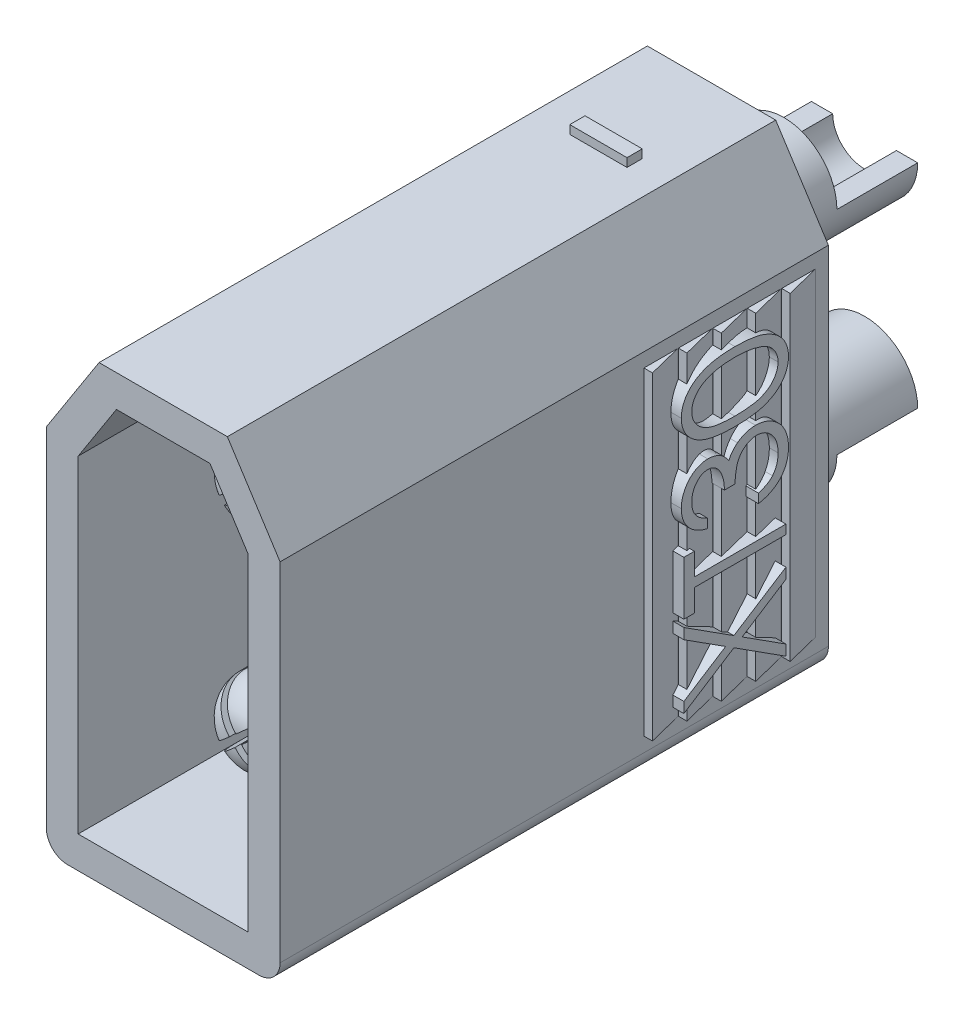
from build123d import *

# Parameters (mm, degrees)
BOSS_EXTRUDE2_DEPTH        = 12.9
BOSS_EXTRUDE3_START        = 1.45
BOSS_EXTRUDE3_DEPTH        = 3.55
BOSS_EXTRUDE4_START        = 1
BOSS_EXTRUDE4_DEPTH        = 7.5
SKETCH7_R                  = 1.25
BOSS_EXTRUDE5_DEPTH        = 5
BOSS_EXTRUDE5_DEPTH_BACK   = 3.6
BOSS_EXTRUDE5_2_DEPTH      = 5
BOSS_EXTRUDE5_2_DEPTH_BACK = 3.6
SKETCH8_R                  = 0.75
CUT_EXTRUDE1_DEPTH         = 3
SKETCH9_W                  = 1.9
SKETCH9_H                  = 1.25
CUT_EXTRUDE2_DEPTH         = 3.95
CUT_EXTRUDE2_DEPTH_BACK    = 3.95
CHAMFER1_SIZE              = 0.75
CHAMFER3_SIZE              = 0.75
SKETCH10_R                 = 0.97
BOSS_EXTRUDE6_DEPTH        = 6.2
BOSS_EXTRUDE6_2_DEPTH      = 6.2
FILLET1_R                  = 0.8
FILLET2_R                  = 0.8
CUT_EXTRUDE3_DEPTH         = 3.1
BOSS_EXTRUDE7_DEPTH        = 0.2
SKETCH13_W                 = 1.346153847
SKETCH13_H                 = 0.358974359
BOSS_EXTRUDE8_DEPTH        = 0.2
BOSS_EXTRUDE9_DEPTH        = 0.3
BOSS_EXTRUDE10_DEPTH       = 0.3


with BuildPart() as part:
    # Sketch3 → Boss-Extrude2 (new body)
    with BuildSketch(Plane.XY):
        with BuildLine():
            Line((2.25, 0.160364397), (-2.25, 0.160364397))
            ThreePointArc((-2.25, 0.160364397), (-2.603553391, 0.306811006), (-2.75, 0.660364397))
            Line((-2.75, 0.660364397), (-2.75, 8.830640811))
            Line((-2.75, 8.830640811), (-1.509463409, 10.760364397))
            Line((-1.509463409, 10.760364397), (1.509463409, 10.760364397))
            Line((1.509463409, 10.760364397), (2.75, 8.830640811))
            Line((2.75, 8.830640811), (2.75, 0.660364397))
            ThreePointArc((2.75, 0.660364397), (2.603553391, 0.306811006), (2.25, 0.160364397))
        make_face()
        Polygon((2, 0.910364397), (-2, 0.910364397), (-2, 8.610364397), (-1.1, 10.010364397), (1.1, 10.010364397), (2, 8.610364397), align=None, mode=Mode.SUBTRACT)
    extrude(amount=BOSS_EXTRUDE2_DEPTH)

    # Sketch4 → Boss-Extrude3 (add)
    with BuildSketch(Plane.XY.offset(BOSS_EXTRUDE3_START)):
        with BuildLine():
            Line((-1.5, 10.010364397), (1.5, 10.010364397))
            ThreePointArc((1.5, 10.010364397), (1.853553391, 9.863917787), (2, 9.510364397))
            Line((2, 9.510364397), (2, 0.910364397))
            Line((2, 0.910364397), (-2, 0.910364397))
            Line((-2, 0.910364397), (-2, 9.510364397))
            ThreePointArc((-2, 9.510364397), (-1.853553391, 9.863917787), (-1.5, 10.010364397))
        make_face()
    extrude(amount=BOSS_EXTRUDE3_DEPTH)

    # Sketch6 → Boss-Extrude4 (add)
    with BuildSketch(Plane(origin=(0, 0, 0), x_dir=(1, 0, 0), z_dir=(0, 1, 0)).offset(BOSS_EXTRUDE4_START)):
        Polygon((2.75, -0.3), (2.75, -1.1), (2.95, -1.1), align=None)
        Polygon((2.75, -1.11), (2.75, -1.91), (2.95, -1.91), align=None)
        Polygon((2.75, -1.92), (2.75, -2.72), (2.95, -2.72), align=None)
        Polygon((2.75, -2.73), (2.75, -3.53), (2.95, -3.53), align=None)
        Polygon((2.75, -3.54), (2.75, -4.34), (2.95, -4.34), align=None)
        Polygon((-2.95, -4.34), (-2.75, -3.54), (-2.75, -4.34), align=None)
        Polygon((-2.95, -3.53), (-2.75, -2.73), (-2.75, -3.53), align=None)
        Polygon((-2.95, -2.72), (-2.75, -1.92), (-2.75, -2.72), align=None)
        Polygon((-2.95, -1.91), (-2.75, -1.11), (-2.75, -1.91), align=None)
        Polygon((-2.95, -1.1), (-2.75, -0.3), (-2.75, -1.1), align=None)
    extrude(amount=BOSS_EXTRUDE4_DEPTH)

    # Sketch12 → Boss-Extrude7 (add)
    with BuildSketch(Plane.XZ.offset(-0.160364397)):
        Polygon((-0.148717949, 2.884615385), (-0.148717949, 3.916666667), (0.165384615, 3.916666667), (0.165384615, 2.884615385), (1.197435897, 2.884615385), (1.197435897, 2.570512821), (0.165384615, 2.570512821), (0.165384615, 1.538461538), (-0.148717949, 1.538461538), (-0.148717949, 2.570512821), (-1.180769231, 2.570512821), (-1.180769231, 2.884615385), align=None)
    extrude(amount=BOSS_EXTRUDE7_DEPTH)

    # Sketch13 → Boss-Extrude8 (add)
    with BuildSketch(Plane(origin=(0, 10.760364397, 0), x_dir=(-1, 0, 0), z_dir=(0, 1, 0))):
        with Locations((-0.052168047, 2.534824587)):
            Rectangle(SKETCH13_W, SKETCH13_H)
    extrude(amount=BOSS_EXTRUDE8_DEPTH)

    # Sketch14 → Boss-Extrude9 (add)
    with BuildSketch(Plane.ZY.offset(2.75)):
        Polygon((3.7, 8.211538462), (3.7, 7.962980769), (2.718269231, 7.334615385), (3.7, 6.70625), (3.7, 6.457692308), (2.524038462, 7.210096154), (1.3, 6.426923077), (1.3, 6.675480769), (2.329807692, 7.334615385), (1.3, 7.99375), (1.3, 8.242307692), (2.524038462, 7.458653846), align=None)
        Polygon((3.453846154, 6.288461538), (3.7, 6.288461538), (3.7, 5.026923077), (3.453846154, 5.026923077), (3.453846154, 5.55), (1.3, 5.55), (1.3, 5.765384615), (3.453846154, 5.765384615), align=None)
        with BuildLine():
            Line((3.146153846, 4.503846154), (3.146153846, 4.719230769))
            add(Edge.make_bspline(
                [(3.146153846, 4.719230769), (3.170313264, 4.713395649), (3.217542949, 4.701988466), (3.285022214, 4.678195844), (3.348878343, 4.652276354), (3.40791565, 4.621152397), (3.463320612, 4.587203537), (3.513836583, 4.548307957), (3.560748331, 4.506260147), (3.602380265, 4.45975161), (3.64007928, 4.410977671), (3.672222176, 4.359251074), (3.699873024, 4.305612519), (3.722652611, 4.24969037), (3.73981297, 4.191318138), (3.752263351, 4.131023539), (3.760348687, 4.068648568), (3.761137781, 4.026307363), (3.761538462, 4.004807692)],
                knots=[0, 0, 0, 0, 7.4513e-05, 0.000145667, 0.000214417, 0.000281078, 0.000345646, 0.000409109, 0.000472075, 0.000534362, 0.000596096, 0.000656791, 0.000716781, 0.000776954, 0.000837647, 0.00089903, 0.000961524, 0.001025992, 0.001025992, 0.001025992, 0.001025992], degree=3))
            add(Edge.make_bspline(
                [(3.761538462, 4.004807692), (3.760592704, 3.973482383), (3.758721818, 3.911515062), (3.741637633, 3.820477544), (3.714603256, 3.732687725), (3.677249843, 3.649106526), (3.631178543, 3.57147103), (3.57634558, 3.502394787), (3.513808916, 3.442814094), (3.444735158, 3.392829378), (3.370914237, 3.353692236), (3.294936987, 3.324833008), (3.216983635, 3.307263856), (3.164350072, 3.304986903), (3.137980769, 3.303846154)],
                knots=[0, 0, 0, 0, 9.3899e-05, 0.00018575, 0.000276839, 0.000368952, 0.000459731, 0.000546978, 0.000632671, 0.00071807, 0.00080195, 0.000882585, 0.000961327, 0.001040384, 0.001040384, 0.001040384, 0.001040384], degree=3))
            add(Edge.make_bspline(
                [(3.137980769, 3.303846154), (3.112604681, 3.304644045), (3.062947616, 3.306205394), (2.990452875, 3.319462792), (2.922127206, 3.341773372), (2.85768298, 3.372678352), (2.797528805, 3.412683987), (2.741529337, 3.461145264), (2.689436199, 3.518404233), (2.659594275, 3.561795504), (2.644230769, 3.584134615)],
                knots=[0, 0, 0, 0, 7.6085e-05, 0.000148886, 0.000220191, 0.000291151, 0.000362622, 0.000436254, 0.000512835, 0.000594098, 0.000594098, 0.000594098, 0.000594098], degree=3))
            add(Edge.make_bspline(
                [(2.644230769, 3.584134615), (2.63190288, 3.558604269), (2.607477766, 3.50802127), (2.559576676, 3.439072335), (2.504269466, 3.376481792), (2.46110879, 3.341576385), (2.439423077, 3.324038462)],
                knots=[0, 0, 0, 0, 8.4934e-05, 0.00016828, 0.000251007, 0.000334546, 0.000334546, 0.000334546, 0.000334546], degree=3))
            add(Edge.make_bspline(
                [(2.439423077, 3.324038462), (2.423613732, 3.312485412), (2.392253932, 3.289568501), (2.341804337, 3.261361383), (2.290962579, 3.235479451), (2.237729623, 3.216431099), (2.183815408, 3.199993125), (2.128065414, 3.189177486), (2.071009313, 3.182234278), (2.032392143, 3.18125931), (2.012980769, 3.180769231)],
                knots=[0, 0, 0, 0, 5.8685e-05, 0.00011641, 0.000173173, 0.000229612, 0.000285747, 0.00034213, 0.000399736, 0.000457959, 0.000457959, 0.000457959, 0.000457959], degree=3))
            add(Edge.make_bspline(
                [(2.012980769, 3.180769231), (1.97937544, 3.182002464), (1.912322928, 3.184463127), (1.813234502, 3.206368134), (1.716541423, 3.240522701), (1.623676369, 3.288177011), (1.536970145, 3.347137911), (1.45974361, 3.417672544), (1.39291464, 3.498066224), (1.33725751, 3.587792791), (1.292734208, 3.684961717), (1.261839895, 3.788901588), (1.241716319, 3.898100993), (1.239558549, 3.972986084), (1.238461538, 4.011057692)],
                knots=[0, 0, 0, 0, 0.000100706, 0.000200938, 0.000302971, 0.000407683, 0.000513164, 0.00061662, 0.000720404, 0.000825792, 0.000932506, 0.001040031, 0.001150374, 0.001264488, 0.001264488, 0.001264488, 0.001264488], degree=3))
            add(Edge.make_bspline(
                [(1.238461538, 4.011057692), (1.239056885, 4.036716641), (1.240228328, 4.087204896), (1.248236511, 4.161429009), (1.262862801, 4.232278174), (1.282545067, 4.299848184), (1.307499405, 4.364199066), (1.338575083, 4.425134453), (1.375131542, 4.483029237), (1.417600288, 4.537337089), (1.465107492, 4.588051536), (1.518496527, 4.633824832), (1.576780462, 4.675420119), (1.640636272, 4.711723643), (1.709238734, 4.744388981), (1.783466275, 4.771255923), (1.862655319, 4.79490317), (1.917840055, 4.805897546), (1.946153846, 4.811538462)],
                knots=[0, 0, 0, 0, 7.6977e-05, 0.000151465, 0.000223595, 0.00029373, 0.000362386, 0.000430329, 0.000498619, 0.000567476, 0.000636857, 0.000706734, 0.000778104, 0.000851332, 0.000926819, 0.001005766, 0.00108792, 0.001174485, 0.001174485, 0.001174485, 0.001174485], degree=3))
            Line((1.946153846, 4.811538462), (1.946153846, 4.596153846))
            add(Edge.make_bspline(
                [(1.946153846, 4.596153846), (1.927674523, 4.590542446), (1.891730634, 4.579627786), (1.840000138, 4.561048839), (1.792577473, 4.539882024), (1.749114761, 4.517174898), (1.709183971, 4.493326821), (1.673840975, 4.466642301), (1.641533408, 4.439097744), (1.623331388, 4.418334759), (1.614423077, 4.408173077)],
                knots=[0, 0, 0, 0, 5.7934e-05, 0.000112687, 0.000164772, 0.000213586, 0.00025976, 0.000304088, 0.00034633, 0.00038682, 0.00038682, 0.00038682, 0.00038682], degree=3))
            add(Edge.make_bspline(
                [(1.614423077, 4.408173077), (1.604063077, 4.394735424), (1.583375055, 4.367901598), (1.556973938, 4.324174811), (1.534097806, 4.278187461), (1.516623272, 4.228943113), (1.501827162, 4.177504413), (1.49214452, 4.123039934), (1.485501203, 4.066030185), (1.484914964, 4.027103719), (1.484615385, 4.007211538)],
                knots=[0, 0, 0, 0, 5.0866e-05, 0.000101575, 0.000152964, 0.000204677, 0.000258103, 0.00031336, 0.000370434, 0.000430081, 0.000430081, 0.000430081, 0.000430081], degree=3))
            add(Edge.make_bspline(
                [(1.484615385, 4.007211538), (1.485037033, 3.98475169), (1.485861529, 3.940833395), (1.493465896, 3.87675431), (1.504492464, 3.815774027), (1.521740161, 3.758514848), (1.542431622, 3.704197617), (1.569520542, 3.654034852), (1.600113099, 3.606551829), (1.635698125, 3.563139581), (1.674161687, 3.524001317), (1.714968099, 3.490181532), (1.756852096, 3.460889731), (1.800790747, 3.437344011), (1.846353049, 3.418718241), (1.893709543, 3.406046248), (1.942461457, 3.397233195), (1.975601388, 3.396515597), (1.992307692, 3.396153846)],
                knots=[0, 0, 0, 0, 6.7351e-05, 0.000131698, 0.000193364, 0.000252999, 0.000310851, 0.000367413, 0.000423685, 0.000480075, 0.000535489, 0.000588058, 0.000638867, 0.000688556, 0.000737302, 0.000786173, 0.000835413, 0.000885471, 0.000885471, 0.000885471, 0.000885471], degree=3))
            add(Edge.make_bspline(
                [(1.992307692, 3.396153846), (2.014669779, 3.397203177), (2.05928268, 3.399296618), (2.12491721, 3.415279923), (2.188157598, 3.441568341), (2.247915784, 3.478376614), (2.303327092, 3.523161948), (2.352574163, 3.575490823), (2.393618756, 3.635491603), (2.421872315, 3.691070581), (2.440702124, 3.740419384), (2.453905233, 3.782567182), (2.464459565, 3.829794668), (2.474668782, 3.881534884), (2.483227542, 3.938006046), (2.490395838, 3.99925903), (2.496122592, 4.065318479), (2.498681403, 4.111049473), (2.5, 4.134615385)],
                knots=[0, 0, 0, 0, 6.7036e-05, 0.000133738, 0.000201416, 0.000271748, 0.000343529, 0.00041462, 0.000486501, 0.000560894, 0.000601072, 0.000644867, 0.000693263, 0.000746158, 0.00080307, 0.000864552, 0.000931149, 0.001001954, 0.001001954, 0.001001954, 0.001001954], degree=3))
            Line((2.5, 4.134615385), (2.746153846, 4.134615385))
            add(Edge.make_bspline(
                [(2.746153846, 4.134615385), (2.746659909, 4.104923977), (2.74765116, 4.046765804), (2.759557156, 3.961798157), (2.776212077, 3.880451678), (2.801133952, 3.804583191), (2.831047314, 3.735657242), (2.864776815, 3.675530146), (2.902990827, 3.62562689), (2.945187826, 3.585822797), (2.990973089, 3.556608006), (3.038193773, 3.534679412), (3.087948546, 3.521823981), (3.121884535, 3.520098217), (3.138942308, 3.519230769)],
                knots=[0, 0, 0, 0, 8.9006e-05, 0.000174341, 0.000256944, 0.000337827, 0.000413394, 0.00048209, 0.000544117, 0.000601265, 0.000655139, 0.000706348, 0.000756954, 0.000808099, 0.000808099, 0.000808099, 0.000808099], degree=3))
            add(Edge.make_bspline(
                [(3.138942308, 3.519230769), (3.151475649, 3.519514904), (3.176410136, 3.520080176), (3.212838313, 3.527210223), (3.248154898, 3.537922039), (3.282199645, 3.552657938), (3.314774944, 3.572345731), (3.345920757, 3.59597764), (3.376159056, 3.623565073), (3.404043204, 3.655829025), (3.430345097, 3.690758195), (3.453082104, 3.728681243), (3.472353977, 3.768761731), (3.488276651, 3.811036515), (3.500246646, 3.855674947), (3.508843236, 3.902458453), (3.514217465, 3.951478695), (3.514991259, 3.984922153), (3.515384615, 4.001923077)],
                knots=[0, 0, 0, 0, 3.7549e-05, 7.4703e-05, 0.000110898, 0.000148144, 0.00018566, 0.000224794, 0.000265285, 0.000308205, 0.000352533, 0.000396314, 0.00044061, 0.000485795, 0.00053163, 0.00057906, 0.000628383, 0.000679381, 0.000679381, 0.000679381, 0.000679381], degree=3))
            add(Edge.make_bspline(
                [(3.515384615, 4.001923077), (3.514432389, 4.029250838), (3.51257247, 4.082628311), (3.496224619, 4.159563101), (3.470323134, 4.231010572), (3.439047168, 4.285439132), (3.408279997, 4.325699299), (3.381810999, 4.355020423), (3.351800577, 4.383288989), (3.317425578, 4.409395714), (3.27986802, 4.434904968), (3.238921049, 4.459573177), (3.194000885, 4.482607996), (3.162411731, 4.496629667), (3.146153846, 4.503846154)],
                knots=[0, 0, 0, 0, 8.1902e-05, 0.000159973, 0.000234813, 0.000309114, 0.000347192, 0.00038668, 0.000427497, 0.000470676, 0.000516013, 0.00056367, 0.000613986, 0.000667343, 0.000667343, 0.000667343, 0.000667343], degree=3))
        make_face()
        with BuildLine():
            add(Edge.make_bspline(
                [(2.499038462, 2.965384615), (2.537505242, 2.965159689), (2.612227517, 2.964722765), (2.721108414, 2.959862134), (2.823252613, 2.951787614), (2.918664999, 2.940721985), (3.007370214, 2.927255947), (3.089131173, 2.909279594), (3.164326392, 2.888836595), (3.233200736, 2.865143267), (3.296683291, 2.838409551), (3.355943811, 2.809309064), (3.410907058, 2.776702805), (3.462398728, 2.742398603), (3.509844149, 2.705142892), (3.553153471, 2.665328627), (3.592352846, 2.622560867), (3.627908811, 2.577685461), (3.658882589, 2.530418809), (3.686792023, 2.482217984), (3.709699001, 2.432232443), (3.728521186, 2.380918072), (3.743602926, 2.328424096), (3.754047002, 2.274533615), (3.760592629, 2.219233611), (3.761220193, 2.181909617), (3.761538462, 2.162980769)],
                knots=[0, 0, 0, 0, 0.000115394, 0.000224154, 0.000326883, 0.000422716, 0.000512269, 0.000595913, 0.00067371, 0.00074593, 0.000814236, 0.000880244, 0.000943816, 0.001005821, 0.001065739, 0.0011246, 0.001182102, 0.001239617, 0.001296154, 0.001351493, 0.001406561, 0.001460863, 0.001515345, 0.00157022, 0.001625383, 0.001682146, 0.001682146, 0.001682146, 0.001682146], degree=3))
            add(Edge.make_bspline(
                [(3.761538462, 2.162980769), (3.76120396, 2.143893584), (3.760538741, 2.105935178), (3.75414518, 2.049816063), (3.74353641, 1.994993425), (3.728504885, 1.941700987), (3.709856421, 1.889500996), (3.686482397, 1.838801745), (3.659274031, 1.789288317), (3.627303373, 1.741747549), (3.591658383, 1.695657527), (3.551363982, 1.652150352), (3.506827031, 1.611222065), (3.458524039, 1.572358998), (3.405528552, 1.536663732), (3.348762306, 1.502670521), (3.28723257, 1.472243982), (3.221965963, 1.442940205), (3.151156597, 1.417646271), (3.075203618, 1.394835131), (2.99320989, 1.376403839), (2.905605608, 1.361051195), (2.812069048, 1.349157552), (2.712800717, 1.340495169), (2.607735307, 1.335919339), (2.535901353, 1.335057601), (2.499038462, 1.334615385)],
                knots=[0, 0, 0, 0, 5.7244e-05, 0.00011384, 0.000169187, 0.000224594, 0.000279799, 0.000335305, 0.000391901, 0.000449104, 0.000506999, 0.000566538, 0.000626757, 0.000688326, 0.000752333, 0.000818295, 0.000886667, 0.000958132, 0.001032807, 0.001112058, 0.001195912, 0.001284754, 0.001378794, 0.001478689, 0.001583607, 0.001694201, 0.001694201, 0.001694201, 0.001694201], degree=3))
            add(Edge.make_bspline(
                [(2.499038462, 1.334615385), (2.46233649, 1.335062738), (2.390824197, 1.335934387), (2.286229632, 1.340437871), (2.187494777, 1.349350593), (2.094344793, 1.360374224), (2.00733274, 1.376077235), (1.925631239, 1.393928791), (1.849945361, 1.416116359), (1.779509438, 1.441065535), (1.714562595, 1.46973345), (1.653564755, 1.500428903), (1.596844827, 1.534213456), (1.543850111, 1.570121601), (1.495128206, 1.608654337), (1.450558698, 1.649755931), (1.410170985, 1.69345767), (1.374038974, 1.739651897), (1.342440476, 1.787940548), (1.314196501, 1.837288706), (1.291278267, 1.888681315), (1.271927958, 1.940976215), (1.256861852, 1.994666843), (1.246546191, 2.049700536), (1.239291373, 2.105897061), (1.238739108, 2.14388698), (1.238461538, 2.162980769)],
                knots=[0, 0, 0, 0, 0.000110113, 0.000214551, 0.000313966, 0.00040747, 0.000495838, 0.000579117, 0.000658232, 0.000732291, 0.000803123, 0.000871066, 0.000937028, 0.001001035, 0.00106298, 0.001123199, 0.001182739, 0.001241308, 0.001298912, 0.001355742, 0.001411685, 0.001467506, 0.001522914, 0.001578733, 0.001635384, 0.001692628, 0.001692628, 0.001692628, 0.001692628], degree=3))
            add(Edge.make_bspline(
                [(1.238461538, 2.162980769), (1.23878287, 2.181908848), (1.239416472, 2.219231325), (1.245917863, 2.274542438), (1.25651944, 2.328348871), (1.270916329, 2.380758187), (1.289213921, 2.431877644), (1.31248778, 2.481206477), (1.339481837, 2.529396148), (1.370192627, 2.576226767), (1.405386394, 2.620805771), (1.444309654, 2.663388571), (1.487938683, 2.702899968), (1.535575131, 2.739688746), (1.586814803, 2.7745993), (1.642162448, 2.806886042), (1.701978203, 2.835929766), (1.765811202, 2.863262607), (1.835191738, 2.887356454), (1.910788018, 2.908478489), (1.993018222, 2.926086659), (2.081638235, 2.940247241), (2.176714385, 2.951921216), (2.278414071, 2.9598239), (2.38664955, 2.964726636), (2.460891856, 2.965161287), (2.499038462, 2.965384615)],
                knots=[0, 0, 0, 0, 5.6763e-05, 0.000111926, 0.000166801, 0.000221154, 0.000274839, 0.000329471, 0.000384573, 0.000440444, 0.000497285, 0.000554786, 0.000613322, 0.00067362, 0.000735226, 0.000799213, 0.000865651, 0.000934588, 0.001007419, 0.001085808, 0.001169922, 0.001259552, 0.001354964, 0.001457214, 0.001565494, 0.001679926, 0.001679926, 0.001679926, 0.001679926], degree=3))
        make_face()
        with BuildLine():
            add(Edge.make_bspline(
                [(2.5, 2.75), (2.467943749, 2.749918093), (2.405728861, 2.749759129), (2.315322054, 2.745606306), (2.230999542, 2.739949004), (2.152654262, 2.732652113), (2.080551391, 2.721815812), (2.014195056, 2.709673993), (1.953936316, 2.69489823), (1.899362024, 2.677415701), (1.849544813, 2.657503965), (1.803192165, 2.635760049), (1.759742093, 2.612413867), (1.719635907, 2.586240321), (1.682474377, 2.557833083), (1.648364296, 2.527145508), (1.617454495, 2.494231565), (1.580777019, 2.448667879), (1.542427413, 2.388811558), (1.509443824, 2.313008014), (1.488581598, 2.235082492), (1.485935923, 2.182176334), (1.484615385, 2.155769231)],
                knots=[0, 0, 0, 0, 9.6159e-05, 0.000186625, 0.000271437, 0.0003497, 0.000422587, 0.000490101, 0.000552017, 0.000608577, 0.000661875, 0.000712848, 0.000762114, 0.00080972, 0.000856357, 0.000902313, 0.000947208, 0.000991657, 0.001077683, 0.001159498, 0.001238907, 0.00131804, 0.00131804, 0.00131804, 0.00131804], degree=3))
            add(Edge.make_bspline(
                [(1.484615385, 2.155769231), (1.485711006, 2.129192542), (1.487899986, 2.076094034), (1.50901912, 1.998516575), (1.540883947, 1.92320439), (1.578562237, 1.864183631), (1.61444452, 1.819281315), (1.645037421, 1.787109665), (1.679292873, 1.757581403), (1.71625239, 1.729575409), (1.756622094, 1.703889185), (1.80020786, 1.680531605), (1.847130725, 1.65921731), (1.879887117, 1.647073964), (1.896634615, 1.640865385)],
                knots=[0, 0, 0, 0, 7.9573e-05, 0.000158981, 0.000239533, 0.000324231, 0.000368005, 0.000411871, 0.000457189, 0.000503535, 0.00055088, 0.00060057, 0.000651778, 0.000705348, 0.000705348, 0.000705348, 0.000705348], degree=3))
            add(Edge.make_bspline(
                [(1.896634615, 1.640865385), (1.918049294, 1.633629887), (1.961530275, 1.618938723), (2.028979636, 1.600004935), (2.099747246, 1.585093804), (2.173410183, 1.571678925), (2.250511692, 1.562522543), (2.330813213, 1.555152614), (2.41437529, 1.550811572), (2.471148998, 1.550273457), (2.5, 1.55)],
                knots=[0, 0, 0, 0, 6.7807e-05, 0.000137678, 0.000210006, 0.0002847, 0.000362222, 0.000442834, 0.000526599, 0.00061315, 0.00061315, 0.00061315, 0.00061315], degree=3))
            add(Edge.make_bspline(
                [(2.5, 1.55), (2.528850382, 1.550301594), (2.585294877, 1.550891648), (2.667873225, 1.55476836), (2.746441917, 1.560997914), (2.821072227, 1.569429478), (2.891631323, 1.581004233), (2.958220173, 1.594904362), (3.020820825, 1.611200667), (3.079594722, 1.629893016), (3.134330614, 1.650959034), (3.185147673, 1.674230668), (3.2323153, 1.699064654), (3.275698105, 1.726043141), (3.315491909, 1.754839941), (3.350898473, 1.786216607), (3.383015255, 1.818928162), (3.419675301, 1.864745666), (3.45705475, 1.924728034), (3.491454128, 1.99936505), (3.511208386, 2.077036348), (3.513993543, 2.12954386), (3.515384615, 2.155769231)],
                knots=[0, 0, 0, 0, 8.655e-05, 0.000169332, 0.000247946, 0.000322966, 0.000394575, 0.000462371, 0.000526973, 0.000588551, 0.000647299, 0.000702804, 0.000756142, 0.000807103, 0.000855953, 0.000903305, 0.000948865, 0.000993314, 0.001079083, 0.001160213, 0.001239037, 0.001317691, 0.001317691, 0.001317691, 0.001317691], degree=3))
            add(Edge.make_bspline(
                [(3.515384615, 2.155769231), (3.513993418, 2.182314751), (3.511208489, 2.235454152), (3.491505929, 2.313915865), (3.457375016, 2.389084556), (3.419433917, 2.448585691), (3.383664241, 2.494345387), (3.352558795, 2.526658121), (3.318345526, 2.556867163), (3.281341328, 2.585298067), (3.241214914, 2.611446417), (3.197771161, 2.634802154), (3.151414205, 2.656533589), (3.101608328, 2.676488074), (3.046951763, 2.693808585), (2.986997143, 2.709289928), (2.920578828, 2.72142438), (2.848274376, 2.732013417), (2.769832785, 2.740086958), (2.68531587, 2.745591783), (2.594752721, 2.749766643), (2.53221683, 2.749920656), (2.5, 2.75)],
                knots=[0, 0, 0, 0, 7.9612e-05, 0.000159369, 0.000240938, 0.0003263, 0.00037045, 0.000414996, 0.000460631, 0.000507268, 0.000554874, 0.00060414, 0.000655113, 0.000708411, 0.000764971, 0.000827005, 0.000894046, 0.000967409, 0.001046199, 0.001130531, 0.001221478, 0.001318117, 0.001318117, 0.001318117, 0.001318117], degree=3))
        make_face(mode=Mode.SUBTRACT)
    extrude(amount=BOSS_EXTRUDE9_DEPTH)

    # Sketch15 → Boss-Extrude10 (add)
    with BuildSketch(Plane(origin=(2.75, 0, 0), x_dir=(0, 0, -1), z_dir=(1, 0, 0))):
        Polygon((-3.7, 1.288461538), (-3.7, 1.537019231), (-2.718269231, 2.165384615), (-3.7, 2.79375), (-3.7, 3.042307692), (-2.524038462, 2.289903846), (-1.3, 3.073076923), (-1.3, 2.824519231), (-2.329807692, 2.165384615), (-1.3, 1.50625), (-1.3, 1.257692308), (-2.524038462, 2.041346154), align=None)
        Polygon((-3.453846154, 3.211538462), (-3.7, 3.211538462), (-3.7, 4.473076923), (-3.453846154, 4.473076923), (-3.453846154, 3.95), (-1.3, 3.95), (-1.3, 3.734615385), (-3.453846154, 3.734615385), align=None)
        with BuildLine():
            Line((-3.146153846, 4.996153846), (-3.146153846, 4.780769231))
            add(Edge.make_bspline(
                [(-3.146153846, 4.780769231), (-3.170313264, 4.786604351), (-3.217542949, 4.798011534), (-3.285022214, 4.821804156), (-3.348878343, 4.847723646), (-3.40791565, 4.878847603), (-3.463320612, 4.912796463), (-3.513836583, 4.951692043), (-3.560748331, 4.993739853), (-3.602380265, 5.04024839), (-3.64007928, 5.089022329), (-3.672222176, 5.140748926), (-3.699873024, 5.194387481), (-3.722652611, 5.25030963), (-3.73981297, 5.308681862), (-3.752263351, 5.368976461), (-3.760348687, 5.431351432), (-3.761137781, 5.473692637), (-3.761538462, 5.495192308)],
                knots=[0, 0, 0, 0, 7.4513e-05, 0.000145667, 0.000214417, 0.000281078, 0.000345646, 0.000409109, 0.000472075, 0.000534362, 0.000596096, 0.000656791, 0.000716781, 0.000776954, 0.000837647, 0.00089903, 0.000961524, 0.001025992, 0.001025992, 0.001025992, 0.001025992], degree=3))
            add(Edge.make_bspline(
                [(-3.761538462, 5.495192308), (-3.760592704, 5.526517617), (-3.758721818, 5.588484938), (-3.741637633, 5.679522456), (-3.714603256, 5.767312275), (-3.677249843, 5.850893474), (-3.631178543, 5.92852897), (-3.57634558, 5.997605213), (-3.513808916, 6.057185906), (-3.444735158, 6.107170622), (-3.370914237, 6.146307764), (-3.294936987, 6.175166992), (-3.216983635, 6.192736144), (-3.164350072, 6.195013097), (-3.137980769, 6.196153846)],
                knots=[0, 0, 0, 0, 9.3899e-05, 0.00018575, 0.000276839, 0.000368952, 0.000459731, 0.000546978, 0.000632671, 0.00071807, 0.00080195, 0.000882585, 0.000961327, 0.001040384, 0.001040384, 0.001040384, 0.001040384], degree=3))
            add(Edge.make_bspline(
                [(-3.137980769, 6.196153846), (-3.112604681, 6.195355955), (-3.062947616, 6.193794606), (-2.990452875, 6.180537208), (-2.922127206, 6.158226628), (-2.85768298, 6.127321648), (-2.797528805, 6.087316013), (-2.741529337, 6.038854736), (-2.689436199, 5.981595767), (-2.659594275, 5.938204496), (-2.644230769, 5.915865385)],
                knots=[0, 0, 0, 0, 7.6085e-05, 0.000148886, 0.000220191, 0.000291151, 0.000362622, 0.000436254, 0.000512835, 0.000594098, 0.000594098, 0.000594098, 0.000594098], degree=3))
            add(Edge.make_bspline(
                [(-2.644230769, 5.915865385), (-2.631947571, 5.941428272), (-2.607571562, 5.992157828), (-2.559006904, 6.060606804), (-2.504311045, 6.12369148), (-2.461150573, 6.158459102), (-2.439423077, 6.175961538)],
                knots=[0, 0, 0, 0, 8.4934e-05, 0.000168552, 0.000250959, 0.000334498, 0.000334498, 0.000334498, 0.000334498], degree=3))
            add(Edge.make_bspline(
                [(-2.439423077, 6.175961538), (-2.423612047, 6.187509888), (-2.392248904, 6.210417473), (-2.341823927, 6.238693268), (-2.290840048, 6.264345232), (-2.237930741, 6.284333954), (-2.183709246, 6.299813177), (-2.12808246, 6.310877885), (-2.071004959, 6.317751581), (-2.032390687, 6.31873596), (-2.012980769, 6.319230769)],
                knots=[0, 0, 0, 0, 5.8685e-05, 0.00011641, 0.000173173, 0.000229781, 0.000285782, 0.000342166, 0.000399772, 0.000457995, 0.000457995, 0.000457995, 0.000457995], degree=3))
            add(Edge.make_bspline(
                [(-2.012980769, 6.319230769), (-1.979374275, 6.318000068), (-1.912319439, 6.315544458), (-1.813248482, 6.293601467), (-1.716418185, 6.259570588), (-1.623756647, 6.211297303), (-1.537142597, 6.152199607), (-1.459073945, 6.082668571), (-1.393021198, 6.001710161), (-1.337163761, 5.912258452), (-1.292929099, 5.814928886), (-1.261046363, 5.711252352), (-1.241923125, 5.601828841), (-1.239628538, 5.526999571), (-1.238461538, 5.488942308)],
                knots=[0, 0, 0, 0, 0.000100706, 0.000200938, 0.000302971, 0.000407902, 0.000513384, 0.000616873, 0.00072035, 0.000825738, 0.000932452, 0.001040118, 0.001150378, 0.001264492, 0.001264492, 0.001264492, 0.001264492], degree=3))
            add(Edge.make_bspline(
                [(-1.238461538, 5.488942308), (-1.239062077, 5.463284974), (-1.240243738, 5.412799897), (-1.248177969, 5.338552782), (-1.263063166, 5.267830621), (-1.281783363, 5.199946675), (-1.307666131, 5.135925478), (-1.338523186, 5.074846144), (-1.375145816, 5.016976404), (-1.41759561, 4.96265993), (-1.465111807, 4.91195475), (-1.518483783, 4.866152665), (-1.576715432, 4.824746924), (-1.640330558, 4.788000613), (-1.709150984, 4.755759082), (-1.783452485, 4.72871617), (-1.862659044, 4.705104367), (-1.917841318, 4.69410501), (-1.946153846, 4.688461538)],
                knots=[0, 0, 0, 0, 7.6977e-05, 0.000151465, 0.000223595, 0.000293596, 0.000362429, 0.000430372, 0.000498662, 0.000567519, 0.0006369, 0.000706777, 0.000778147, 0.000850959, 0.000926881, 0.001005828, 0.001087982, 0.001174547, 0.001174547, 0.001174547, 0.001174547], degree=3))
            Line((-1.946153846, 4.688461538), (-1.946153846, 4.903846154))
            add(Edge.make_bspline(
                [(-1.946153846, 4.903846154), (-1.927674523, 4.909457554), (-1.891730634, 4.920372214), (-1.840000138, 4.938951161), (-1.792577473, 4.960117976), (-1.749114761, 4.982825102), (-1.709183971, 5.006673179), (-1.673840975, 5.033357699), (-1.641533408, 5.060902256), (-1.623331388, 5.081665241), (-1.614423077, 5.091826923)],
                knots=[0, 0, 0, 0, 5.7934e-05, 0.000112687, 0.000164772, 0.000213586, 0.00025976, 0.000304088, 0.00034633, 0.00038682, 0.00038682, 0.00038682, 0.00038682], degree=3))
            add(Edge.make_bspline(
                [(-1.614423077, 5.091826923), (-1.604067348, 5.105266076), (-1.583387857, 5.1321029), (-1.556922628, 5.175807161), (-1.534269024, 5.221931471), (-1.515855225, 5.270860473), (-1.502033164, 5.322600731), (-1.492084694, 5.376942365), (-1.485517159, 5.433974536), (-1.48492036, 5.472897878), (-1.484615385, 5.492788462)],
                knots=[0, 0, 0, 0, 5.0866e-05, 0.000101575, 0.000152964, 0.000204845, 0.000258143, 0.0003134, 0.000370474, 0.00043012, 0.00043012, 0.00043012, 0.00043012], degree=3))
            add(Edge.make_bspline(
                [(-1.484615385, 5.492788462), (-1.48503772, 5.515248006), (-1.485863559, 5.559165707), (-1.49345833, 5.623249039), (-1.504519185, 5.684214146), (-1.521602373, 5.741384152), (-1.542709242, 5.795507929), (-1.569211006, 5.845826774), (-1.60030453, 5.893001247), (-1.635645667, 5.936427125), (-1.674334692, 5.975475473), (-1.714800798, 6.009856853), (-1.756873367, 6.039085193), (-1.800785221, 6.062662504), (-1.846354521, 6.081280024), (-1.893709147, 6.093954218), (-1.942461558, 6.102766686), (-1.975601422, 6.103484363), (-1.992307692, 6.103846154)],
                knots=[0, 0, 0, 0, 6.7351e-05, 0.000131698, 0.000193364, 0.000252999, 0.000310404, 0.000367391, 0.000423262, 0.000479651, 0.000535065, 0.000587943, 0.000638752, 0.000688442, 0.000737187, 0.000786058, 0.000835299, 0.000885356, 0.000885356, 0.000885356, 0.000885356], degree=3))
            add(Edge.make_bspline(
                [(-1.992307692, 6.103846154), (-2.014668323, 6.102794596), (-2.059278321, 6.100696713), (-2.124934651, 6.084746761), (-2.18821688, 6.058275185), (-2.248305389, 6.021942445), (-2.303316966, 5.976632765), (-2.352751361, 5.924488333), (-2.39350346, 5.864090554), (-2.421685413, 5.808542998), (-2.440909842, 5.759331314), (-2.453715767, 5.717218212), (-2.464559344, 5.670070734), (-2.474647781, 5.618459552), (-2.483233842, 5.561995623), (-2.490393946, 5.500740468), (-2.496123116, 5.43468166), (-2.498681582, 5.388950575), (-2.5, 5.365384615)],
                knots=[0, 0, 0, 0, 6.7036e-05, 0.000133738, 0.000201416, 0.000272159, 0.000343567, 0.000414658, 0.000486935, 0.000561328, 0.000601058, 0.000645312, 0.00069324, 0.000746136, 0.000803047, 0.00086453, 0.000931126, 0.001001931, 0.001001931, 0.001001931, 0.001001931], degree=3))
            Line((-2.5, 5.365384615), (-2.746153846, 5.365384615))
            add(Edge.make_bspline(
                [(-2.746153846, 5.365384615), (-2.746730338, 5.395066113), (-2.747859148, 5.453184545), (-2.758772232, 5.538305504), (-2.776292024, 5.619355998), (-2.801324781, 5.695170906), (-2.830810345, 5.764140042), (-2.864880102, 5.82421666), (-2.903441563, 5.873819218), (-2.945756429, 5.913465928), (-2.990892973, 5.943600213), (-3.038225163, 5.96527192), (-3.08794064, 5.978188277), (-3.12188189, 5.979905883), (-3.138942308, 5.980769231)],
                knots=[0, 0, 0, 0, 8.9006e-05, 0.00017428, 0.000256985, 0.000337411, 0.000413418, 0.000481698, 0.00054402, 0.000601169, 0.000654905, 0.000706114, 0.00075672, 0.000807865, 0.000807865, 0.000807865, 0.000807865], degree=3))
            add(Edge.make_bspline(
                [(-3.138942308, 5.980769231), (-3.151477704, 5.980491282), (-3.176416281, 5.979938317), (-3.212965293, 5.972687545), (-3.248395398, 5.962292795), (-3.282302632, 5.947200869), (-3.314756392, 5.927646943), (-3.346112693, 5.904061066), (-3.375966368, 5.875771032), (-3.404471434, 5.844085888), (-3.430403155, 5.809000096), (-3.453097703, 5.771332087), (-3.472349685, 5.731234601), (-3.488277828, 5.68896449), (-3.500246317, 5.644324772), (-3.508843329, 5.597541626), (-3.514217441, 5.548521284), (-3.514991251, 5.51507784), (-3.515384615, 5.498076923)],
                knots=[0, 0, 0, 0, 3.7549e-05, 7.4703e-05, 0.000111358, 0.000148164, 0.00018568, 0.000224814, 0.000265632, 0.000308871, 0.000352526, 0.000396308, 0.000440604, 0.000485789, 0.000531623, 0.000579054, 0.000628377, 0.000679375, 0.000679375, 0.000679375, 0.000679375], degree=3))
            add(Edge.make_bspline(
                [(-3.515384615, 5.498076923), (-3.514430539, 5.470750065), (-3.512567005, 5.417374355), (-3.496244938, 5.340426984), (-3.470202824, 5.268893726), (-3.439117325, 5.214215783), (-3.408431313, 5.173839161), (-3.381631962, 5.144986404), (-3.351849455, 5.116652339), (-3.317249426, 5.090701018), (-3.280175056, 5.064456005), (-3.238741674, 5.040562592), (-3.194030089, 5.017344517), (-3.162421654, 5.003354197), (-3.146153846, 4.996153846)],
                knots=[0, 0, 0, 0, 8.1902e-05, 0.000159973, 0.000234813, 0.000309532, 0.00034761, 0.000386741, 0.000427559, 0.000470737, 0.000516347, 0.000563758, 0.000614074, 0.00066743, 0.00066743, 0.00066743, 0.00066743], degree=3))
        make_face()
        with BuildLine():
            add(Edge.make_bspline(
                [(-2.499038462, 6.534615385), (-2.537505242, 6.534840311), (-2.612227517, 6.535277235), (-2.721108414, 6.540137866), (-2.823252612, 6.548212387), (-2.918665, 6.559278014), (-3.007370212, 6.572744056), (-3.089131182, 6.590720395), (-3.16432636, 6.611163442), (-3.233200844, 6.634856607), (-3.296682915, 6.661590889), (-3.355945145, 6.690689379), (-3.410902324, 6.723302714), (-3.46241569, 6.757581622), (-3.50969849, 6.794860577), (-3.55329551, 6.834340247), (-3.59283909, 6.876810232), (-3.628356308, 6.921858611), (-3.659499726, 6.96918007), (-3.687100855, 7.017481491), (-3.709835759, 7.067625914), (-3.728433536, 7.118953214), (-3.74361533, 7.17157157), (-3.754043667, 7.22546755), (-3.760593493, 7.280766088), (-3.761220484, 7.318090281), (-3.761538462, 7.337019231)],
                knots=[0, 0, 0, 0, 0.000115394, 0.000224154, 0.000326883, 0.000422716, 0.000512269, 0.000595913, 0.00067371, 0.00074593, 0.000814236, 0.000880244, 0.000943816, 0.001005821, 0.001065739, 0.001124275, 0.001182103, 0.001239619, 0.001296156, 0.001351913, 0.001406344, 0.001461097, 0.001515579, 0.001570454, 0.001625617, 0.00168238, 0.00168238, 0.00168238, 0.00168238], degree=3))
            add(Edge.make_bspline(
                [(-3.761538462, 7.337019231), (-3.761273604, 7.356115673), (-3.760746632, 7.394110871), (-3.753329179, 7.450082401), (-3.743755258, 7.505079003), (-3.728400265, 7.558266269), (-3.710026025, 7.610649868), (-3.685781507, 7.660927126), (-3.659413711, 7.710873095), (-3.627247217, 7.758218797), (-3.591697949, 7.804378834), (-3.551340441, 7.84764905), (-3.507291591, 7.889135547), (-3.458568983, 7.927271395), (-3.405919678, 7.963691045), (-3.348902322, 7.997011969), (-3.287643275, 8.027927182), (-3.222426524, 8.057017809), (-3.151510029, 8.082456793), (-3.075336115, 8.105074084), (-2.99321499, 8.12361278), (-2.90560412, 8.138943957), (-2.812069484, 8.150843868), (-2.712800592, 8.159504422), (-2.607735341, 8.164080772), (-2.535901364, 8.164942437), (-2.499038462, 8.165384615)],
                knots=[0, 0, 0, 0, 5.7244e-05, 0.000113895, 0.000169152, 0.00022456, 0.000279764, 0.000335472, 0.000391836, 0.00044904, 0.000506934, 0.000566474, 0.000626341, 0.000688285, 0.000751896, 0.000818272, 0.000886215, 0.00095768, 0.001032354, 0.001112067, 0.00119592, 0.001284763, 0.001378803, 0.001478698, 0.001583616, 0.001694209, 0.001694209, 0.001694209, 0.001694209], degree=3))
            add(Edge.make_bspline(
                [(-2.499038462, 8.165384615), (-2.462336675, 8.164932708), (-2.390664663, 8.164050215), (-2.286067227, 8.159602572), (-2.187333416, 8.15063233), (-2.094357965, 8.139575379), (-2.007097768, 8.124072848), (-1.925609682, 8.105393579), (-1.849605204, 8.084111331), (-1.779628894, 8.058281927), (-1.714525314, 8.029868408), (-1.653716701, 7.99898637), (-1.596714403, 7.965853481), (-1.543926227, 7.929980041), (-1.495399183, 7.891216897), (-1.451199254, 7.849759479), (-1.410585056, 7.806111463), (-1.37464414, 7.75968232), (-1.342232747, 7.711895622), (-1.314908078, 7.661944579), (-1.291232856, 7.611107572), (-1.271876178, 7.558877043), (-1.256864848, 7.505333632), (-1.246545376, 7.450299335), (-1.23929158, 7.394102972), (-1.238739177, 7.356113031), (-1.238461538, 7.337019231)],
                knots=[0, 0, 0, 0, 0.000110113, 0.000215031, 0.000313968, 0.000407471, 0.00049584, 0.000579694, 0.000658214, 0.000732436, 0.000803268, 0.000871211, 0.000936929, 0.001000936, 0.001062505, 0.001123051, 0.001182591, 0.00124116, 0.00129903, 0.001355626, 0.001411769, 0.001467139, 0.001522547, 0.001578366, 0.001635017, 0.001692261, 0.001692261, 0.001692261, 0.001692261], degree=3))
            add(Edge.make_bspline(
                [(-1.238461538, 7.337019231), (-1.238781325, 7.318090695), (-1.239411882, 7.280767319), (-1.245935583, 7.225462798), (-1.256423929, 7.171783409), (-1.271109599, 7.119464261), (-1.289085492, 7.068236945), (-1.31250514, 7.01879946), (-1.339477152, 6.970602308), (-1.370193712, 6.923773367), (-1.405386871, 6.8791953), (-1.444306581, 6.836606923), (-1.487950875, 6.797117517), (-1.53563262, 6.760161804), (-1.587222629, 6.725520507), (-1.642755524, 6.693188994), (-1.702326128, 6.663480286), (-1.766309902, 6.636289253), (-1.835673227, 6.612181369), (-1.911060084, 6.590968785), (-1.993236179, 6.574026946), (-2.081784288, 6.559666118), (-2.176884334, 6.548158598), (-2.278570723, 6.540141219), (-2.38665036, 6.535280925), (-2.460892131, 6.53484128), (-2.499038462, 6.534615385)],
                knots=[0, 0, 0, 0, 5.6763e-05, 0.000111926, 0.000166801, 0.00022069, 0.000274828, 0.00032946, 0.000384562, 0.000440433, 0.000497274, 0.000554775, 0.000613311, 0.000673608, 0.000735613, 0.0007996, 0.000866252, 0.000935189, 0.00100802, 0.001086409, 0.001169952, 0.001259582, 0.001355471, 0.001457242, 0.001565522, 0.001679954, 0.001679954, 0.001679954, 0.001679954], degree=3))
        make_face()
        with BuildLine():
            add(Edge.make_bspline(
                [(-2.5, 6.75), (-2.467943878, 6.750083703), (-2.405729238, 6.750246153), (-2.315480445, 6.754367232), (-2.231163965, 6.760103355), (-2.152812707, 6.767319727), (-2.080700506, 6.77812727), (-2.014527565, 6.790389088), (-1.95441637, 6.805096391), (-1.899841619, 6.822583575), (-1.850030513, 6.842503179), (-1.803655408, 6.864213701), (-1.760166674, 6.887743646), (-1.71966982, 6.913575328), (-1.682659877, 6.942219458), (-1.648198725, 6.97234809), (-1.617484895, 7.005318502), (-1.580642315, 7.050919041), (-1.542572669, 7.111123295), (-1.509420878, 7.186977032), (-1.48858724, 7.264921185), (-1.485937802, 7.31782489), (-1.484615385, 7.344230769)],
                knots=[0, 0, 0, 0, 9.6159e-05, 0.000186625, 0.000270957, 0.000349699, 0.000422586, 0.000489627, 0.000551544, 0.000608103, 0.000661401, 0.000712374, 0.000761641, 0.00080965, 0.000856288, 0.000901923, 0.000946817, 0.000991267, 0.001077699, 0.001159514, 0.001238923, 0.001318056, 0.001318056, 0.001318056, 0.001318056], degree=3))
            add(Edge.make_bspline(
                [(-1.484615385, 7.344230769), (-1.485773319, 7.370789502), (-1.48808508, 7.423812757), (-1.508261217, 7.501685311), (-1.541061209, 7.576658902), (-1.578534422, 7.635827265), (-1.614449869, 7.68071659), (-1.645035935, 7.712890918), (-1.679293287, 7.742418435), (-1.716252276, 7.770424636), (-1.756622126, 7.796110802), (-1.800207851, 7.819468398), (-1.847130727, 7.840782689), (-1.879887118, 7.852926036), (-1.896634615, 7.859134615)],
                knots=[0, 0, 0, 0, 7.9573e-05, 0.000158863, 0.000239605, 0.000324304, 0.000368078, 0.000411944, 0.000457261, 0.000503607, 0.000550953, 0.000600642, 0.00065185, 0.000705421, 0.000705421, 0.000705421, 0.000705421], degree=3))
            add(Edge.make_bspline(
                [(-1.896634615, 7.859134615), (-1.918049294, 7.866370113), (-1.961530275, 7.881061277), (-2.028979636, 7.899995065), (-2.099747246, 7.914906196), (-2.173410183, 7.928321075), (-2.250511692, 7.937477457), (-2.330813213, 7.944847386), (-2.41437529, 7.949188428), (-2.471148998, 7.949726543), (-2.5, 7.95)],
                knots=[0, 0, 0, 0, 6.7807e-05, 0.000137678, 0.000210006, 0.0002847, 0.000362222, 0.000442834, 0.000526599, 0.00061315, 0.00061315, 0.00061315, 0.00061315], degree=3))
            add(Edge.make_bspline(
                [(-2.5, 7.95), (-2.528846335, 7.949622727), (-2.585275934, 7.948884702), (-2.667916972, 7.946063681), (-2.746409151, 7.938778945), (-2.821090618, 7.93068812), (-2.89154797, 7.918758598), (-2.958371031, 7.905896097), (-3.020731981, 7.888615284), (-3.079607056, 7.870155945), (-3.134327738, 7.849029043), (-3.185147813, 7.825771755), (-3.232317306, 7.800936723), (-3.275690478, 7.773949591), (-3.315518912, 7.745186264), (-3.350886159, 7.713615449), (-3.38351264, 7.681242128), (-3.420089335, 7.635200441), (-3.457677926, 7.575413909), (-3.491328249, 7.500506098), (-3.511243419, 7.422979743), (-3.514005212, 7.3704615), (-3.515384615, 7.344230769)],
                knots=[0, 0, 0, 0, 8.655e-05, 0.000169311, 0.000247965, 0.000322985, 0.000394594, 0.000462292, 0.000527018, 0.000588595, 0.000647344, 0.000702849, 0.000756186, 0.000807148, 0.000855998, 0.00090335, 0.000949245, 0.000993695, 0.001079464, 0.001160399, 0.001239223, 0.001317877, 0.001317877, 0.001317877, 0.001317877], degree=3))
            add(Edge.make_bspline(
                [(-3.515384615, 7.344230769), (-3.51400178, 7.317682331), (-3.51123359, 7.26453709), (-3.491420351, 7.186182825), (-3.45777638, 7.110768967), (-3.420161753, 7.050785281), (-3.383652879, 7.005302924), (-3.352579624, 6.973027576), (-3.318941561, 6.942481101), (-3.281603297, 6.914578708), (-3.241249134, 6.8889002), (-3.198322785, 6.864460906), (-3.151861029, 6.843040712), (-3.102088981, 6.823057157), (-3.047511229, 6.805540804), (-2.98718253, 6.791001549), (-2.920851564, 6.777765276), (-2.84821247, 6.768233002), (-2.76984449, 6.759839201), (-2.685312385, 6.754430205), (-2.594753685, 6.750227274), (-2.532217157, 6.750077275), (-2.5, 6.75)],
                knots=[0, 0, 0, 0, 7.9612e-05, 0.000159369, 0.000240744, 0.000326513, 0.000370962, 0.000415508, 0.000460785, 0.000507131, 0.00055514, 0.000604219, 0.000655192, 0.00070849, 0.000765049, 0.000826966, 0.00089457, 0.000967865, 0.001046655, 0.001130988, 0.001221934, 0.001318574, 0.001318574, 0.001318574, 0.001318574], degree=3))
        make_face(mode=Mode.SUBTRACT)
    extrude(amount=BOSS_EXTRUDE10_DEPTH)


with BuildPart() as body_2:
    # Sketch7 → Boss-Extrude5 (new body, two sides)
    with BuildSketch(Plane.XY) as boss_extrude5_sk:
        with Locations((0, 2.960364397)):
            Circle(SKETCH7_R)
    extrude(amount=BOSS_EXTRUDE5_DEPTH)
    extrude(boss_extrude5_sk.sketch, amount=-BOSS_EXTRUDE5_DEPTH_BACK)


with BuildPart() as body_3:
    # Sketch7 → Boss-Extrude5 2 (new body, two sides)
    with BuildSketch(Plane.XY) as boss_extrude5_2_sk:
        with Locations((0, 7.960364397)):
            Circle(SKETCH7_R)
    extrude(amount=BOSS_EXTRUDE5_2_DEPTH)
    extrude(boss_extrude5_2_sk.sketch, amount=-BOSS_EXTRUDE5_2_DEPTH_BACK)


with BuildPart() as cut_extrude1_tool:
    # Sketch8 → Cut-Extrude1 (new body)
    with BuildSketch(Plane(origin=(0, 0, -3.6), x_dir=(-1, 0, 0), z_dir=(0, 0, -1))):
        with Locations((0, 2.960364397)):
            Circle(SKETCH8_R)
        with Locations((0, 7.960364397)):
            Circle(SKETCH8_R)
    extrude(amount=-CUT_EXTRUDE1_DEPTH)


with BuildPart() as body_2_1:
    add(body_2.part)

    # Cut-Extrude1: cut by cut_extrude1_tool
    add(cut_extrude1_tool.part, mode=Mode.SUBTRACT)


with BuildPart() as body_3_1:
    add(body_3.part)

    # Cut-Extrude1: cut by cut_extrude1_tool
    add(cut_extrude1_tool.part, mode=Mode.SUBTRACT)


with BuildPart() as cut_extrude2_tool:
    # Sketch9 → Cut-Extrude2 (new body, two sides)
    with BuildSketch(Plane(origin=(0, 0, 0), x_dir=(0, 0, -1), z_dir=(1, 0, 0))) as cut_extrude2_sk:
        with Locations((2.65, 8.585364397)):
            Rectangle(SKETCH9_W, SKETCH9_H)
        with Locations((2.65, 2.335364397)):
            Rectangle(SKETCH9_W, SKETCH9_H)
    extrude(amount=CUT_EXTRUDE2_DEPTH)
    extrude(cut_extrude2_sk.sketch, amount=-CUT_EXTRUDE2_DEPTH_BACK)


with BuildPart() as body_2_2:
    add(body_2_1.part)

    # Cut-Extrude2: cut by cut_extrude2_tool
    add(cut_extrude2_tool.part, mode=Mode.SUBTRACT)

    # Chamfer3
    chamfer3_edges = [body_2_2.edges().sort_by_distance(p)[0] for p in [
        (0.75, 2.960364397, -0.6),
    ]]
    chamfer(chamfer3_edges, length=CHAMFER3_SIZE)


with BuildPart() as body_3_2:
    add(body_3_1.part)

    # Cut-Extrude2: cut by cut_extrude2_tool
    add(cut_extrude2_tool.part, mode=Mode.SUBTRACT)

    # Chamfer1
    chamfer1_edges = [body_3_2.edges().sort_by_distance(p)[0] for p in [
        (0.75, 7.960364397, -0.6),
    ]]
    chamfer(chamfer1_edges, length=CHAMFER1_SIZE)


with BuildPart() as body_4:
    # Sketch10 → Boss-Extrude6 (new body)
    with BuildSketch(Plane.XY.offset(5)):
        with Locations((0, 7.960364397)):
            Circle(SKETCH10_R)
    extrude(amount=BOSS_EXTRUDE6_DEPTH)

    # Fillet1
    fillet1_edges = [body_4.edges().sort_by_distance(p)[0] for p in [
        (-0.97, 7.960364397, 11.2),
    ]]
    fillet(fillet1_edges, radius=FILLET1_R)


with BuildPart() as body_5:
    # Sketch10 → Boss-Extrude6 2 (new body)
    with BuildSketch(Plane.XY.offset(5)):
        with Locations((0, 2.960364397)):
            Circle(SKETCH10_R)
    extrude(amount=BOSS_EXTRUDE6_2_DEPTH)

    # Fillet2
    fillet2_edges = [body_5.edges().sort_by_distance(p)[0] for p in [
        (-0.97, 2.960364397, 11.2),
    ]]
    fillet(fillet2_edges, radius=FILLET2_R)


with BuildPart() as cut_extrude3_tool:
    # Sketch11 → Cut-Extrude3 (new body)
    with BuildSketch(Plane.XY.offset(11.2)):
        Polygon((-0.603280235, 3.801056379), (0.009350336, 3.101476307), (0.708930408, 3.714106877), (0.840691982, 3.563644631), (0.14111191, 2.951014061), (0.753742481, 2.251433989), (0.603280235, 2.119672415), (-0.009350336, 2.819252486), (-0.708930408, 2.206621916), (-0.840691982, 2.357084162), (-0.14111191, 2.969714733), (-0.753742481, 3.669294804), align=None)
        Polygon((-0.840691982, 7.357084162), (-0.14111191, 7.969714733), (-0.753742481, 8.669294804), (-0.603280235, 8.801056379), (0.009350336, 8.101476307), (0.708930408, 8.714106877), (0.840691982, 8.563644631), (0.14111191, 7.951014061), (0.753742481, 7.251433989), (0.603280235, 7.119672415), (-0.009350336, 7.819252486), (-0.708930408, 7.206621916), align=None)
    extrude(amount=-CUT_EXTRUDE3_DEPTH)


with BuildPart() as body_4_1:
    add(body_4.part)

    # Cut-Extrude3: cut by cut_extrude3_tool
    add(cut_extrude3_tool.part, mode=Mode.SUBTRACT)


with BuildPart() as body_5_1:
    add(body_5.part)

    # Cut-Extrude3: cut by cut_extrude3_tool
    add(cut_extrude3_tool.part, mode=Mode.SUBTRACT)


solid = Compound([part.part, body_2_2.part, body_3_2.part, body_4_1.part, body_5_1.part])
